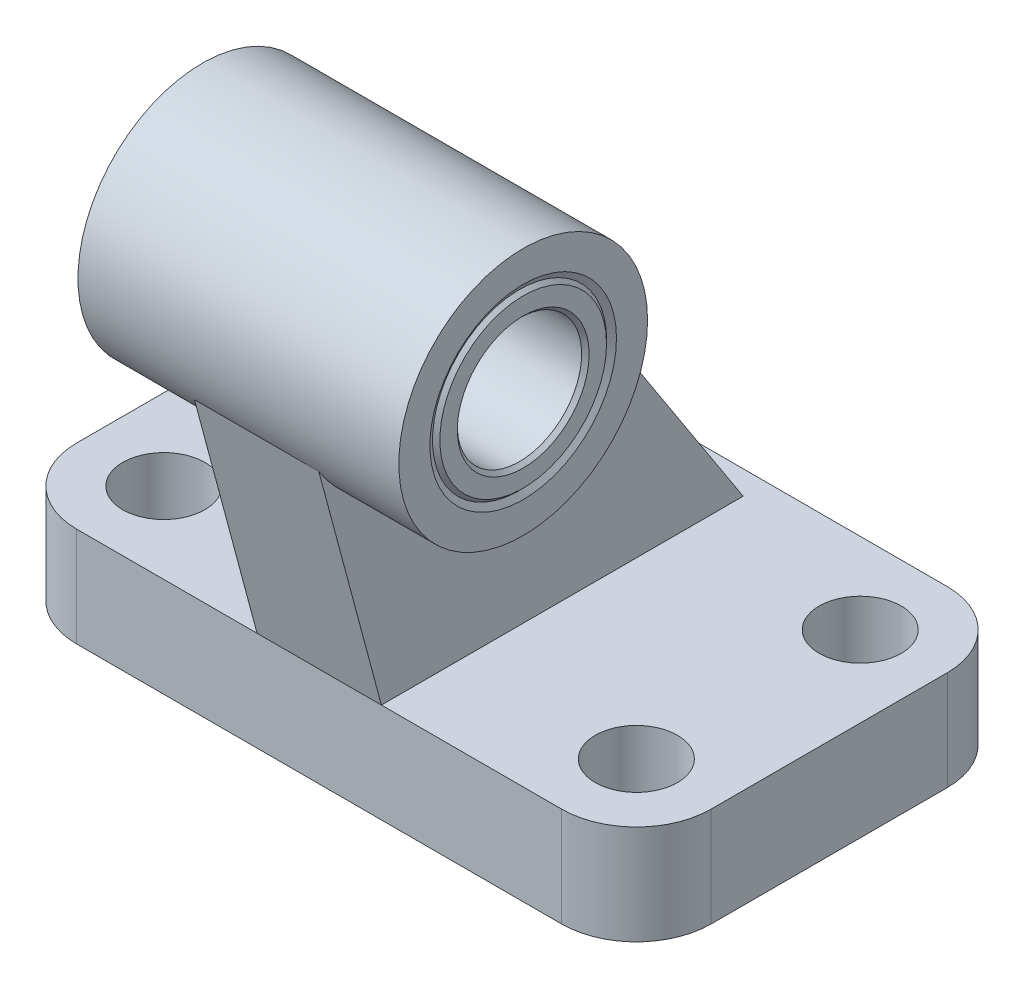
from build123d import *

# Parameters (mm, degrees)
BOSS_EXTRUDE1_DEPTH      = 8
BOSS_EXTRUDE2_DEPTH      = 5
BOSS_EXTRUDE2_DEPTH_BACK = 5
SKETCH3_R                = 10
BOSS_EXTRUDE3_DEPTH      = 12.9
BOSS_EXTRUDE3_DEPTH_BACK = 12.9
SKETCH4_W                = 3.3
SKETCH4_H                = 8
SKETCH5_W                = 3.3
SKETCH5_H                = 8
SKETCH6_W                = 3.3
SKETCH6_H                = 8
SKETCH7_W                = 3.3
SKETCH7_H                = 8


with BuildPart() as part:
    # Sketch1 → Boss-Extrude1 (new body)
    with BuildSketch(Plane(origin=(0, 0, 0), x_dir=(1, 0, 0), z_dir=(0, 1, 0))):
        with BuildLine():
            Line((-19.5, -15.5), (19.5, -15.5))
            ThreePointArc((19.5, -15.5), (23.742640687, -13.742640687), (25.5, -9.5))
            Line((25.5, -9.5), (25.5, 9.5))
            ThreePointArc((25.5, 9.5), (23.742640687, 13.742640687), (19.5, 15.5))
            Line((19.5, 15.5), (-19.5, 15.5))
            ThreePointArc((-19.5, 15.5), (-23.742640687, 13.742640687), (-25.5, 9.5))
            Line((-25.5, 9.5), (-25.5, -9.5))
            ThreePointArc((-25.5, -9.5), (-23.742640687, -13.742640687), (-19.5, -15.5))
        make_face()
    extrude(amount=BOSS_EXTRUDE1_DEPTH)

    # Sketch2 → Boss-Extrude2 (add, two sides)
    with BuildSketch(Plane(origin=(0, 0, 0), x_dir=(0, 0, -1), z_dir=(1, 0, 0))) as boss_extrude2_sk:
        Polygon((-21.265544457, 29.517304845), (-15.5, 8), (13.585782237, 8), (-3.482172222, 34.282345074), align=None)
    extrude(amount=BOSS_EXTRUDE2_DEPTH)
    extrude(boss_extrude2_sk.sketch, amount=-BOSS_EXTRUDE2_DEPTH_BACK)

    # Sketch3 → Boss-Extrude3 (add, two sides)
    with BuildSketch(Plane(origin=(0, 0, 0), x_dir=(0, 0, -1), z_dir=(1, 0, 0))) as boss_extrude3_sk:
        with Locations((-12, 32)):
            Circle(SKETCH3_R)
    extrude(amount=BOSS_EXTRUDE3_DEPTH)
    extrude(boss_extrude3_sk.sketch, amount=-BOSS_EXTRUDE3_DEPTH_BACK)

    # Sketch4 → Cut-Revolve1 (revolve, cut)
    with BuildSketch(Plane.XY.offset(9)):
        with Locations((-20.65, 4)):
            Rectangle(SKETCH4_W, SKETCH4_H)
    revolve(axis=Axis((-19, 8, 9), (0, -1, 0)), mode=Mode.SUBTRACT)

    # Sketch5 → Cut-Revolve2 (revolve, cut)
    with BuildSketch(Plane.XY.offset(9)):
        with Locations((17.35, 4)):
            Rectangle(SKETCH5_W, SKETCH5_H)
    revolve(axis=Axis((19, 8, 9), (0, -1, 0)), mode=Mode.SUBTRACT)

    # Sketch6 → Cut-Revolve3 (revolve, cut)
    with BuildSketch(Plane.XY.offset(-9)):
        with Locations((-20.65, 4)):
            Rectangle(SKETCH6_W, SKETCH6_H)
    revolve(axis=Axis((-19, 8, -9), (0, -1, 0)), mode=Mode.SUBTRACT)

    # Sketch7 → Cut-Revolve4 (revolve, cut)
    with BuildSketch(Plane.XY.offset(-9)):
        with Locations((17.35, 4)):
            Rectangle(SKETCH7_W, SKETCH7_H)
    revolve(axis=Axis((19, 8, -9), (0, -1, 0)), mode=Mode.SUBTRACT)

    # Sketch8 → Cut-Revolve5 (revolve, cut)
    with BuildSketch(Plane.XY.offset(12)):
        Polygon((-12.9, 32), (-12.9, 39.5), (-12.611324865, 39), (12.611324865, 39), (12.9, 39.5), (12.9, 32), align=None)
    revolve(axis=Axis((12.9, 32, 12), (-1, 0, 0)), mode=Mode.SUBTRACT)

    # Sketch9 → Revolve1 (revolve)
    with BuildSketch(Plane.XY.offset(12)):
        Polygon((-12.9, 37.3), (-12.6, 37), (12.6, 37), (12.9, 37.3), (12.9, 38.7), (12.6, 39), (-12.6, 39), (-12.9, 38.7), align=None)
    revolve(axis=Axis((12.9, 32, 12), (-1, 0, 0)))


solid = part.part
